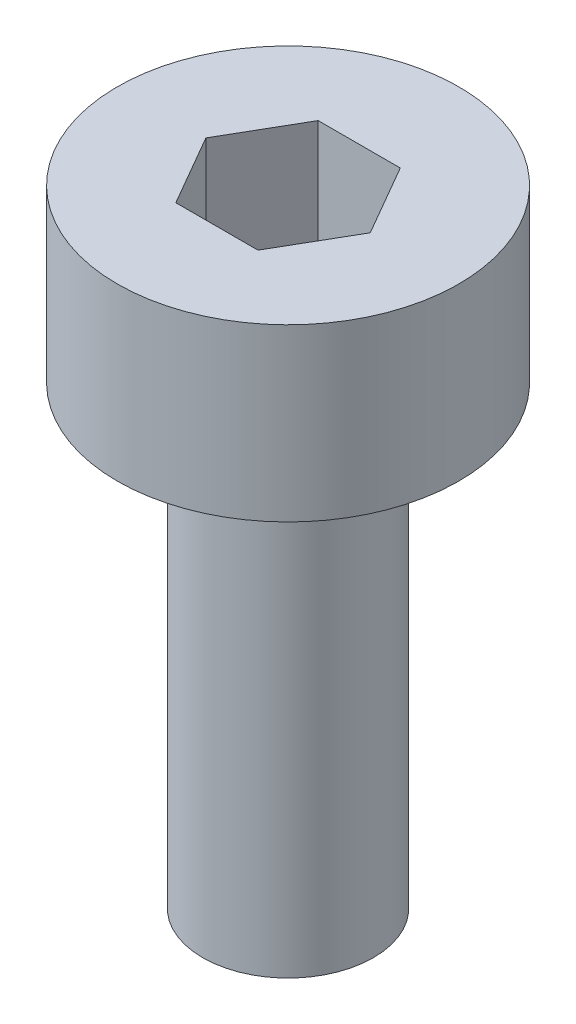
from build123d import *

# Parameters (mm, degrees)
SKETCH1_R           = 1.5
BOSS_EXTRUDE1_DEPTH = 8
SKETCH2_R           = 3
BOSS_EXTRUDE2_DEPTH = 3
CUT_EXTRUDE1_DEPTH  = 2


with BuildPart() as part:
    # Sketch1 → Boss-Extrude1 (new body)
    with BuildSketch(Plane(origin=(0, 0, 0), x_dir=(1, 0, 0), z_dir=(0, 1, 0))):
        Circle(SKETCH1_R)
    extrude(amount=BOSS_EXTRUDE1_DEPTH)

    # Sketch2 → Boss-Extrude2 (add)
    with BuildSketch(Plane(origin=(0, 8, 0), x_dir=(1, 0, 0), z_dir=(0, 1, 0))):
        Circle(SKETCH2_R)
    extrude(amount=BOSS_EXTRUDE2_DEPTH)

    # Sketch3 → Cut-Extrude1 (cut)
    with BuildSketch(Plane(origin=(0, 11, 0), x_dir=(1, 0, 0), z_dir=(0, 1, 0))):
        Polygon((1.443375673, 0), (0.721687836, 1.25), (-0.721687836, 1.25), (-1.443375673, 0), (-0.721687836, -1.25), (0.721687836, -1.25), align=None)
    extrude(amount=-CUT_EXTRUDE1_DEPTH, mode=Mode.SUBTRACT)


solid = part.part
